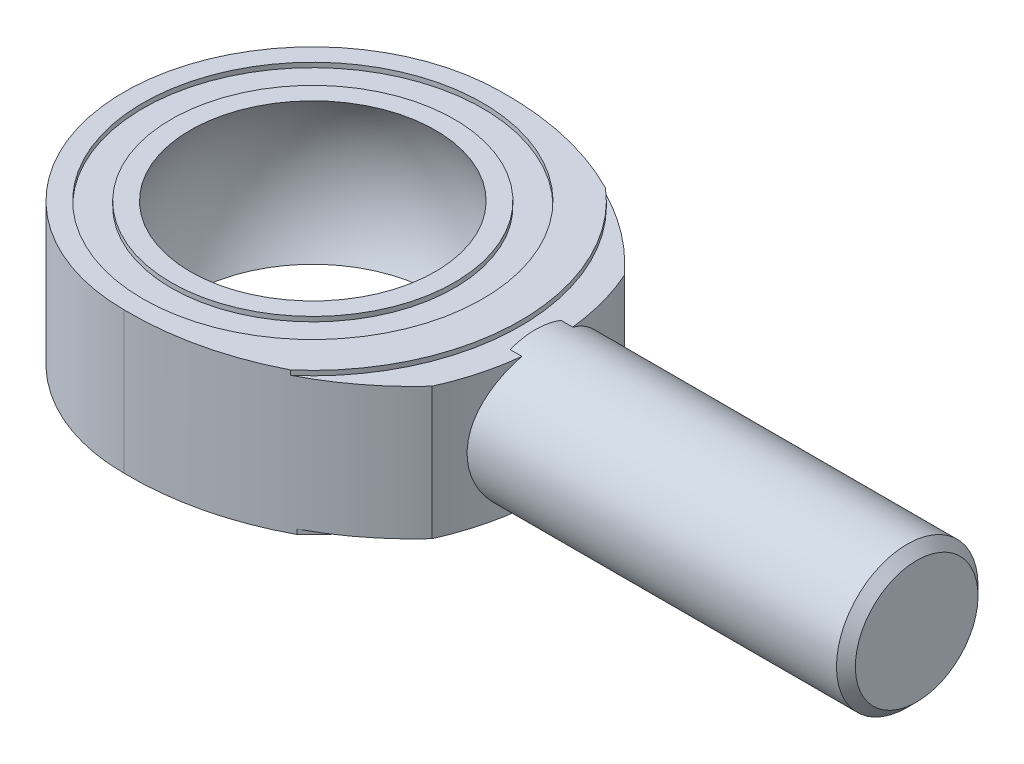
from build123d import *

# Parameters (mm, degrees)
SKETCH2_R                = 15.875
BOSS_EXTRUDE1_DEPTH      = 8.89
SKETCH3_R                = 13.97
BOSS_EXTRUDE2_DEPTH      = 0.3175
SKETCH4_R                = 14.0462
BOSS_EXTRUDE3_DEPTH      = 0.3175
CUT_EXTRUDE2_DEPTH       = 10.525
SKETCH7_R                = 11.43
SKETCH7_R_2              = 9.525
CUT_EXTRUDE3_DEPTH       = 0.3175
SKETCH9_R                = 4.7625
BOSS_EXTRUDE4_DEPTH      = 25.4
BOSS_EXTRUDE4_DEPTH_BACK = 0.254


with BuildPart() as part:
    # Sketch2 → Boss-Extrude1 (new body)
    with BuildSketch(Plane(origin=(0, 0, 0), x_dir=(1, 0, 0), z_dir=(0, 1, 0))):
        Circle(SKETCH2_R)
    extrude(amount=BOSS_EXTRUDE1_DEPTH)

    # Sketch3 → Boss-Extrude2 (add)
    with BuildSketch(Plane(origin=(0, 8.89, 0), x_dir=(1, 0, 0), z_dir=(0, 1, 0))):
        Circle(SKETCH3_R)
    extrude(amount=BOSS_EXTRUDE2_DEPTH)

    # Sketch4 → Boss-Extrude3 (add)
    with BuildSketch(Plane(origin=(0, 0, 0), x_dir=(-1, 0, 0), z_dir=(0, -1, 0))):
        Circle(SKETCH4_R)
    extrude(amount=BOSS_EXTRUDE3_DEPTH)

    # Sketch5 → Cut-Extrude2 (cut, through all)
    with BuildSketch(Plane(origin=(0, -0.3175, 0), x_dir=(-1, 0, 0), z_dir=(0, -1, 0))):
        with BuildLine():
            ThreePointArc((15.875, 0), (3.303921778, 15.527386319), (-14.499768616, 6.463152102))
            ThreePointArc((-14.499768616, 6.463152102), (-12.112281343, 8.677516697), (-9.382547241, 10.452920248))
            ThreePointArc((-9.382547241, 10.452920248), (5.723049859, 12.827409511), (14.0462, 0))
            ThreePointArc((14.0462, 0), (5.723049859, -12.827409511), (-9.382547241, -10.452920248))
            ThreePointArc((-9.382547241, -10.452920248), (-12.112281343, -8.677516697), (-14.499768616, -6.463152102))
            ThreePointArc((-14.499768616, -6.463152102), (3.303921778, -15.527386319), (15.875, 0))
        make_face()
        with BuildLine():
            ThreePointArc((14.0462, 0), (5.723049859, 12.827409511), (-9.382547241, 10.452920248))
            ThreePointArc((-9.382547241, 10.452920248), (-4.835884527, 12.180274323), (0, 12.7))
            ThreePointArc((0, 12.7), (8.980256121, 8.980256121), (12.7, 0))
            ThreePointArc((12.7, 0), (8.980256121, -8.980256121), (0, -12.7))
            ThreePointArc((0, -12.7), (-4.835884527, -12.180274323), (-9.382547241, -10.452920248))
            ThreePointArc((-9.382547241, -10.452920248), (5.723049859, -12.827409511), (14.0462, 0))
        make_face()
    extrude(amount=-CUT_EXTRUDE2_DEPTH, mode=Mode.SUBTRACT)

    # Sketch6 → Cut-Revolve1 (revolve, cut)
    with BuildSketch(Plane(origin=(0, 0, 0), x_dir=(0, 0, -1), z_dir=(1, 0, 0))):
        with BuildLine():
            Line((0, -5.08), (0, 0))
            Line((0, 0), (0, 4.445))
            Line((0, 4.445), (0, 13.97))
            ThreePointArc((0, 13.97), (-9.525, 4.445), (0, -5.08))
        make_face()
    revolve(axis=Axis((0, -5.08, 0), (0, 1, 0)), mode=Mode.SUBTRACT)

    # Sketch7 → Cut-Extrude3 (cut)
    with BuildSketch(Plane(origin=(0, 9.2075, 0), x_dir=(1, 0, 0), z_dir=(0, 1, 0))):
        Circle(SKETCH7_R)
        Circle(SKETCH7_R_2, mode=Mode.SUBTRACT)
    extrude(amount=-CUT_EXTRUDE3_DEPTH, mode=Mode.SUBTRACT)

    # Sketch9 → Boss-Extrude4 (add, two sides)
    with BuildSketch(Plane(origin=(15.24, 0, 0), x_dir=(0, 0, -1), z_dir=(1, 0, 0))) as boss_extrude4_sk:
        with Locations((0, 4.445)):
            Circle(SKETCH9_R)
    extrude(amount=BOSS_EXTRUDE4_DEPTH)
    extrude(boss_extrude4_sk.sketch, amount=-BOSS_EXTRUDE4_DEPTH_BACK)

    # Sketch11 → Cut-Revolve2 (revolve, cut)
    with BuildSketch(Plane.XY):
        Polygon((40.64, -0.3175), (40.64, 0.3175), (40.005, -0.3175), align=None)
    revolve(axis=Axis((40.64, 4.445, 0), (-1, 0, 0)), mode=Mode.SUBTRACT)


solid = part.part
